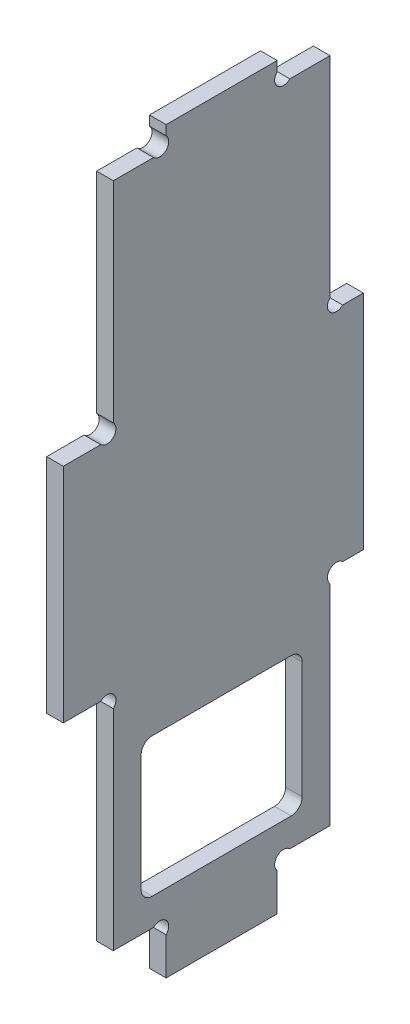
from build123d import *

# Parameters (mm, degrees)
EXTRUSION1_DEPTH        = 3
ESQUISSE2_W             = 29
ESQUISSE2_H             = 25
ENL_V_MAT_EXTRU_1_DEPTH = 4
CONG_1_R                = 2


with BuildPart() as part:
    # Esquisse1 → Extrusion1 (new body)
    with BuildSketch(Plane(origin=(0, 0, 0), x_dir=(0, 0, -1), z_dir=(1, 0, 0))):
        with BuildLine():
            Line((18.5, 6.7372583), (18.5, 0))
            Line((18.5, 0), (38.5, 0))
            Line((38.5, 0), (38.5, 6.7372583))
            ThreePointArc((38.5, 6.7372583), (38.5, 9), (40.7627417, 9))
            Line((40.7627417, 9), (48, 9))
            Line((48, 9), (48, 46.7372583))
            ThreePointArc((48, 46.7372583), (48, 49), (50.2627417, 49))
            Line((50.2627417, 49), (54, 49))
            Line((54, 49), (54, 89))
            Line((54, 89), (50.2627417, 89))
            ThreePointArc((50.2627417, 89), (48, 89), (48, 91.2627417))
            Line((48, 91.2627417), (48, 129))
            Line((48, 129), (40.7627417, 129))
            ThreePointArc((40.7627417, 129), (38.5, 129), (38.5, 131.2627417))
            Line((38.5, 131.2627417), (38.5, 133))
            Line((38.5, 133), (18.5, 133))
            Line((18.5, 133), (18.5, 131.2627417))
            ThreePointArc((18.5, 131.2627417), (18.5, 129), (16.2372583, 129))
            Line((16.2372583, 129), (9, 129))
            Line((9, 129), (9, 91.2627417))
            ThreePointArc((9, 91.2627417), (9, 89), (6.7372583, 89))
            Line((6.7372583, 89), (0, 89))
            Line((0, 89), (0, 49))
            Line((0, 49), (6.7372583, 49))
            ThreePointArc((6.7372583, 49), (9, 49), (9, 46.7372583))
            Line((9, 46.7372583), (9, 9))
            Line((9, 9), (16.2372583, 9))
            ThreePointArc((16.2372583, 9), (18.5, 9), (18.5, 6.7372583))
        make_face()
    extrude(amount=EXTRUSION1_DEPTH)

    # Esquisse2 → Enlèv. mat.-Extru.1 (cut, through all)
    with BuildSketch(Plane(origin=(3, 0, 0), x_dir=(0, 0, -1), z_dir=(1, 0, 0))):
        with Locations((28.5, 26.5)):
            Rectangle(ESQUISSE2_W, ESQUISSE2_H)
    extrude(amount=-ENL_V_MAT_EXTRU_1_DEPTH, mode=Mode.SUBTRACT)

    # Congé1
    cong_1_edges = [part.edges().sort_by_distance(p)[0] for p in [
        (1.5, 14, -14),
        (1.5, 39, -14),
        (1.5, 39, -43),
        (1.5, 14, -43),
    ]]
    fillet(cong_1_edges, radius=CONG_1_R)


solid = part.part
